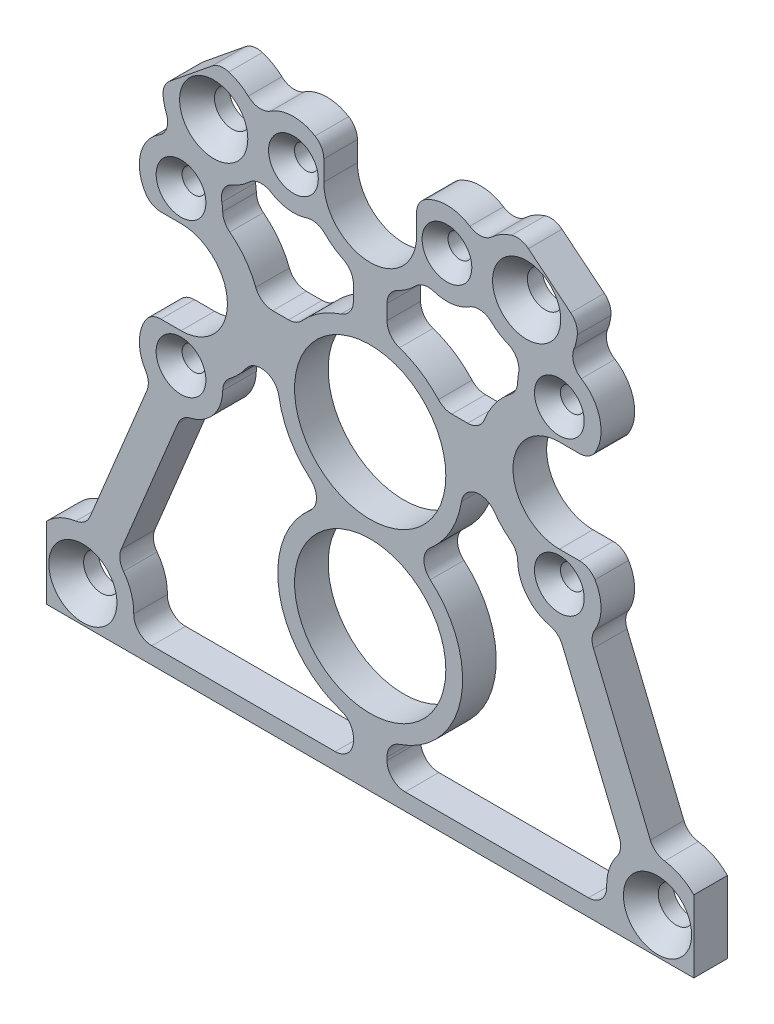
from build123d import *

# Parameters (mm, degrees)
SKETCH1_R                                       = 8.763
SKETCH1_R_2                                     = 14.2875
BOSS_EXTRUDE1_DEPTH                             = 6.35
CSK_FOR_1_4_FLAT_HEAD_MACHINE_SCREW1_AT_COUNT   = 2
CSK_FOR_1_4_FLAT_HEAD_MACHINE_SCREW1_AT_PITCH   = 59.115294704
CSK_FOR_1_4_FLAT_HEAD_MACHINE_SCREW1_2_COUNT    = 2
CSK_FOR_1_4_FLAT_HEAD_MACHINE_SCREW1_2_PITCH    = 91.669390453
CSK_FOR_1_4_FLAT_HEAD_MACHINE_SCREW1_3_COUNT    = 2
CSK_FOR_1_4_FLAT_HEAD_MACHINE_SCREW1_3_PITCH    = 121.739996634
CSK_FOR_M4_FLAT_HEAD_MACHINE_SCREW1_D           = 4.5
CSK_FOR_M4_FLAT_HEAD_MACHINE_SCREW1_CSINK_D     = 9.4
CSK_FOR_M4_FLAT_HEAD_MACHINE_SCREW1_CSINK_ANGLE = 90
CUT_EXTRUDE1_DEPTH                              = 7.35
FILLET1_R                                       = 3.429


with BuildPart() as part:
    # Sketch1 → Boss-Extrude1 (new body)
    with BuildSketch(Plane.XY):
        with BuildLine():
            Line((-61.136251226, -26.9875), (61.136251226, -26.9875))
            Line((61.136251226, -26.9875), (61.136251226, 39.238858696))
            ThreePointArc((61.136251226, 39.238858696), (58.669756239, 50.157391007), (51.749294704, 58.955411096))
            Line((51.749294704, 58.955411096), (16.013043478, 87.979052401))
            ThreePointArc((16.013043478, 87.979052401), (0, 93.6625), (-16.013043478, 87.979052401))
            Line((-16.013043478, 87.979052401), (-51.749294704, 58.955411096))
            ThreePointArc((-51.749294704, 58.955411096), (-58.669756239, 50.157391007), (-61.136251226, 39.238858696))
            Line((-61.136251226, 39.238858696), (-61.136251226, -26.9875))
        make_face()
        with Locations((0, 68.2625)):
            Circle(SKETCH1_R, mode=Mode.SUBTRACT)
        with Locations((-35.736251226, 39.238858696)):
            Circle(SKETCH1_R, mode=Mode.SUBTRACT)
        with Locations((35.736251226, 39.238858696)):
            Circle(SKETCH1_R, mode=Mode.SUBTRACT)
        with Locations((0, 31.75)):
            Circle(SKETCH1_R_2, mode=Mode.SUBTRACT)
        Circle(SKETCH1_R_2, mode=Mode.SUBTRACT)
    extrude(amount=BOSS_EXTRUDE1_DEPTH)

    # Sketch3 → CSK for 1/4 Flat Head Machine Screw1 (revolve, cut)
    with BuildSketch(Plane(origin=(29.557647352, 68.1437626, 6.35), x_dir=(0, -1, 0), z_dir=(1, 0, 0))):
        Polygon((0, 0), (0, 6.35), (3.3782, 6.35), (3.3782, 3.520932584), (6.4389, 0), align=None)
    csk_for_1_4_flat_head_machine_screw1 = revolve(axis=Axis((29.557647352, 68.1437626, 12.7), (0, 0, -1)), mode=Mode.SUBTRACT)

    # CSK for 1/4 Flat Head Machine Screw1 at: CSK for 1/4 Flat Head Machine Screw1 ×2
    with Locations(*[(-i * CSK_FOR_1_4_FLAT_HEAD_MACHINE_SCREW1_AT_PITCH, 0, 0) for i in range(1, CSK_FOR_1_4_FLAT_HEAD_MACHINE_SCREW1_AT_COUNT)]):
        add(csk_for_1_4_flat_head_machine_screw1, mode=Mode.SUBTRACT)

    # CSK for 1_4 Flat Head Machine Screw1 2: CSK for 1/4 Flat Head Machine Screw1 ×2
    with Locations(*[Vector(0.269671302, -0.962952433, 0) * (i * CSK_FOR_1_4_FLAT_HEAD_MACHINE_SCREW1_2_PITCH) for i in range(1, CSK_FOR_1_4_FLAT_HEAD_MACHINE_SCREW1_2_COUNT)]):
        add(csk_for_1_4_flat_head_machine_screw1, mode=Mode.SUBTRACT)

    # CSK for 1_4 Flat Head Machine Screw1 3: CSK for 1/4 Flat Head Machine Screw1 ×2
    with Locations(*[Vector(-0.688647124, -0.725096641, 0) * (i * CSK_FOR_1_4_FLAT_HEAD_MACHINE_SCREW1_3_PITCH) for i in range(1, CSK_FOR_1_4_FLAT_HEAD_MACHINE_SCREW1_3_COUNT)]):
        add(csk_for_1_4_flat_head_machine_screw1, mode=Mode.SUBTRACT)

    # CSK for M4 Flat Head Machine Screw1 (through all)
    with Locations(Plane.XY.offset(6.35)):
        with Locations((-35.736251226, 24.738858696), (-35.736251226, 53.738858696), (35.736251226, 24.738858696), (35.736251226, 53.738858696), (-14.5, 68.2625), (14.5, 68.2625)):
            CounterSinkHole(CSK_FOR_M4_FLAT_HEAD_MACHINE_SCREW1_D / 2, CSK_FOR_M4_FLAT_HEAD_MACHINE_SCREW1_CSINK_D / 2, counter_sink_angle=CSK_FOR_M4_FLAT_HEAD_MACHINE_SCREW1_CSINK_ANGLE)

    # Sketch4 → Cut-Extrude1 (cut, through all)
    with BuildSketch(Plane.XY.offset(6.35)):
        with BuildLine():
            Line((61.136251226, -13.391925569), (61.136251226, 39.238858696))
            ThreePointArc((61.136251226, 39.238858696), (58.669756239, 50.157391007), (51.749294704, 58.955411096))
            Line((51.749294704, 58.955411096), (39.111158828, 69.219630477))
            ThreePointArc((39.111158828, 69.219630477), (39.08774663, 66.877160471), (38.498499596, 64.609892998))
            ThreePointArc((38.498499596, 64.609892998), (38.432488313, 62.270894789), (39.882184939, 60.434144996))
            ThreePointArc((39.882184939, 60.434144996), (43.571824705, 54.525886809), (41.130920447, 48.001858696))
            Line((41.130920447, 48.001858696), (35.736251226, 48.001858696))
            ThreePointArc((35.736251226, 48.001858696), (44.499251226, 39.238858696), (35.736251226, 30.475858696))
            Line((35.736251226, 30.475858696), (41.130920447, 30.475858696))
            ThreePointArc((41.130920447, 30.475858696), (43.608568344, 24.944402337), (41.422948522, 19.291189574))
            Line((41.422948522, 19.291189574), (53.746779924, -10.53030152))
            ThreePointArc((53.746779924, -10.53030152), (57.750061185, -11.16436705), (61.136251226, -13.391925569))
        make_face()
        with BuildLine():
            ThreePointArc((45.397790415, -23.8125), (44.905828652, -17.988292794), (47.878154567, -12.955530668))
            Line((47.878154567, -12.955530668), (35.554323165, 16.865960425))
            ThreePointArc((35.554323165, 16.865960425), (29.599090224, 19.80419763), (28.007866426, 26.251370972))
            ThreePointArc((28.007866426, 26.251370972), (25.497755457, 28.122385631), (23.427004795, 30.470436871))
            ThreePointArc((23.427004795, 30.470436871), (19.849344023, 31.818944393), (17.247390288, 29.017522275))
            ThreePointArc((17.247390288, 29.017522275), (13.911017368, 21.194314232), (7.274838916, 15.875))
            ThreePointArc((7.274838916, 15.875), (17.329643638, -2.149966889), (3.175, -17.171437949))
            Line((3.175, -17.171437949), (3.175, -23.8125))
            Line((3.175, -23.8125), (45.397790415, -23.8125))
        make_face()
        with BuildLine():
            Line((28.651179354, 77.71483302), (16.013043478, 87.979052401))
            ThreePointArc((16.013043478, 87.979052401), (0, 93.6625), (-16.013043478, 87.979052401))
            Line((-16.013043478, 87.979052401), (-28.651179354, 77.71483302))
            ThreePointArc((-28.651179354, 77.71483302), (-25.632241671, 76.919767583), (-23.027224381, 75.199302907))
            ThreePointArc((-23.027224381, 75.199302907), (-20.983031368, 74.298676038), (-18.817882168, 74.848205626))
            ThreePointArc((-18.817882168, 74.848205626), (-13.573654608, 76.082826669), (-8.763, 73.657169221))
            Line((-8.763, 73.657169221), (-8.763, 68.2625))
            ThreePointArc((-8.763, 68.2625), (0, 77.0255), (8.763, 68.2625))
            Line((8.763, 68.2625), (8.763, 73.657169221))
            ThreePointArc((8.763, 73.657169221), (13.573654608, 76.082826669), (18.817882168, 74.848205626))
            ThreePointArc((18.817882168, 74.848205626), (20.983031368, 74.298676038), (23.027224381, 75.199302907))
            ThreePointArc((23.027224381, 75.199302907), (25.632241671, 76.919767583), (28.651179354, 77.71483302))
        make_face()
        with BuildLine():
            ThreePointArc((-47.878154567, -12.955530668), (-44.905828652, -17.988292794), (-45.397790415, -23.8125))
            Line((-45.397790415, -23.8125), (-3.175, -23.8125))
            Line((-3.175, -23.8125), (-3.175, -17.171437949))
            ThreePointArc((-3.175, -17.171437949), (-17.329643638, -2.149966889), (-7.274838916, 15.875))
            ThreePointArc((-7.274838916, 15.875), (-13.911017368, 21.194314232), (-17.247390288, 29.017522275))
            ThreePointArc((-17.247390288, 29.017522275), (-19.849344023, 31.818944393), (-23.427004795, 30.470436871))
            ThreePointArc((-23.427004795, 30.470436871), (-25.497755457, 28.122385631), (-28.007866426, 26.251370972))
            ThreePointArc((-28.007866426, 26.251370972), (-29.599090224, 19.80419763), (-35.554323165, 16.865960425))
            Line((-35.554323165, 16.865960425), (-47.878154567, -12.955530668))
        make_face()
        with BuildLine():
            Line((-61.136251226, 39.238858696), (-61.136251226, -13.391925569))
            ThreePointArc((-61.136251226, -13.391925569), (-57.750061185, -11.16436705), (-53.746779924, -10.53030152))
            Line((-53.746779924, -10.53030152), (-41.422948522, 19.291189574))
            ThreePointArc((-41.422948522, 19.291189574), (-43.608568344, 24.944402337), (-41.130920447, 30.475858696))
            Line((-41.130920447, 30.475858696), (-35.736251226, 30.475858696))
            ThreePointArc((-35.736251226, 30.475858696), (-44.499251226, 39.238858696), (-35.736251226, 48.001858696))
            Line((-35.736251226, 48.001858696), (-41.130920447, 48.001858696))
            ThreePointArc((-41.130920447, 48.001858696), (-43.571824705, 54.525886809), (-39.882184939, 60.434144996))
            ThreePointArc((-39.882184939, 60.434144996), (-38.432488313, 62.270894789), (-38.498499596, 64.609892998))
            ThreePointArc((-38.498499596, 64.609892998), (-39.08774663, 66.877160471), (-39.111158828, 69.219630477))
            Line((-39.111158828, 69.219630477), (-51.749294704, 58.955411096))
            ThreePointArc((-51.749294704, 58.955411096), (-58.669756239, 50.157391007), (-61.136251226, 39.238858696))
        make_face()
        with BuildLine():
            ThreePointArc((3.175, 48.921437949), (9.103017974, 46.65214649), (13.828269016, 42.413858696))
            Line((13.828269016, 42.413858696), (20.960523021, 42.413858696))
            ThreePointArc((20.960523021, 42.413858696), (23.461072841, 48.054910228), (28.007866426, 52.22634642))
            ThreePointArc((28.007866426, 52.22634642), (27.861410275, 53.788908621), (28.027716066, 55.34948301))
            ThreePointArc((28.027716066, 55.34948301), (27.696068277, 57.665790385), (25.955854812, 59.230056092))
            ThreePointArc((25.955854812, 59.230056092), (23.056445738, 61.061287695), (20.984218704, 63.793659793))
            ThreePointArc((20.984218704, 63.793659793), (15.921927409, 60.516936919), (10.025869621, 61.781930399))
            ThreePointArc((10.025869621, 61.781930399), (7.062905205, 58.637988892), (3.175, 56.754449818))
            Line((3.175, 56.754449818), (3.175, 48.921437949))
        make_face()
        with BuildLine():
            Line((-20.960523021, 42.413858696), (-13.828269016, 42.413858696))
            ThreePointArc((-13.828269016, 42.413858696), (-9.103017974, 46.65214649), (-3.175, 48.921437949))
            Line((-3.175, 48.921437949), (-3.175, 56.754449818))
            ThreePointArc((-3.175, 56.754449818), (-7.062905205, 58.637988892), (-10.025869621, 61.781930399))
            ThreePointArc((-10.025869621, 61.781930399), (-15.921927409, 60.516936919), (-20.984218704, 63.793659793))
            ThreePointArc((-20.984218704, 63.793659793), (-23.056445738, 61.061287695), (-25.955854812, 59.230056092))
            ThreePointArc((-25.955854812, 59.230056092), (-27.696068277, 57.665790385), (-28.027716066, 55.34948301))
            ThreePointArc((-28.027716066, 55.34948301), (-27.861410275, 53.788908621), (-28.007866426, 52.22634642))
            ThreePointArc((-28.007866426, 52.22634642), (-23.461072841, 48.054910228), (-20.960523021, 42.413858696))
        make_face()
    extrude(amount=-CUT_EXTRUDE1_DEPTH, mode=Mode.SUBTRACT)

    # Fillet1
    fillet1_edges = [part.edges().sort_by_distance(p)[0] for p in [
        (-7.274838916, 15.875, 3.175),
        (-3.175, -17.171437949, 3.175),
        (-3.175, -23.8125, 3.175),
        (-45.397790415, -23.8125, 3.175),
        (-47.878154567, -12.955530668, 3.175),
        (-35.554323165, 16.865960425, 3.175),
        (-28.007866426, 26.251370972, 3.175),
        (8.763, 73.657169221, 3.175),
        (-8.763, 73.657169221, 3.175),
        (-28.651179354, 77.71483302, 3.175),
        (28.651179354, 77.71483302, 3.175),
        (-41.130920447, 48.001858696, 3.175),
        (-41.130920447, 30.475858696, 3.175),
        (-41.422948522, 19.291189574, 3.175),
        (-53.746779924, -10.53030152, 3.175),
        (-39.111158828, 69.219630477, 3.175),
        (41.422948522, 19.291189574, 3.175),
        (41.130920447, 30.475858696, 3.175),
        (41.130920447, 48.001858696, 3.175),
        (39.111158828, 69.219630477, 3.175),
        (53.746779924, -10.53030152, 3.175),
        (28.007866426, 26.251370972, 3.175),
        (35.554323165, 16.865960425, 3.175),
        (47.878154567, -12.955530668, 3.175),
        (45.397790415, -23.8125, 3.175),
        (3.175, -23.8125, 3.175),
        (3.175, -17.171437949, 3.175),
        (7.274838916, 15.875, 3.175),
        (28.007866426, 52.22634642, 3.175),
        (20.960523021, 42.413858696, 3.175),
        (13.828269016, 42.413858696, 3.175),
        (3.175, 48.921437949, 3.175),
        (3.175, 56.754449818, 3.175),
        (10.025869621, 61.781930399, 3.175),
        (20.984218704, 63.793659793, 3.175),
        (-20.984218704, 63.793659793, 3.175),
        (-10.025869621, 61.781930399, 3.175),
        (-3.175, 56.754449818, 3.175),
        (-3.175, 48.921437949, 3.175),
        (-13.828269016, 42.413858696, 3.175),
        (-20.960523021, 42.413858696, 3.175),
        (-28.007866426, 52.22634642, 3.175),
    ]]
    fillet(fillet1_edges, radius=FILLET1_R)


solid = part.part
